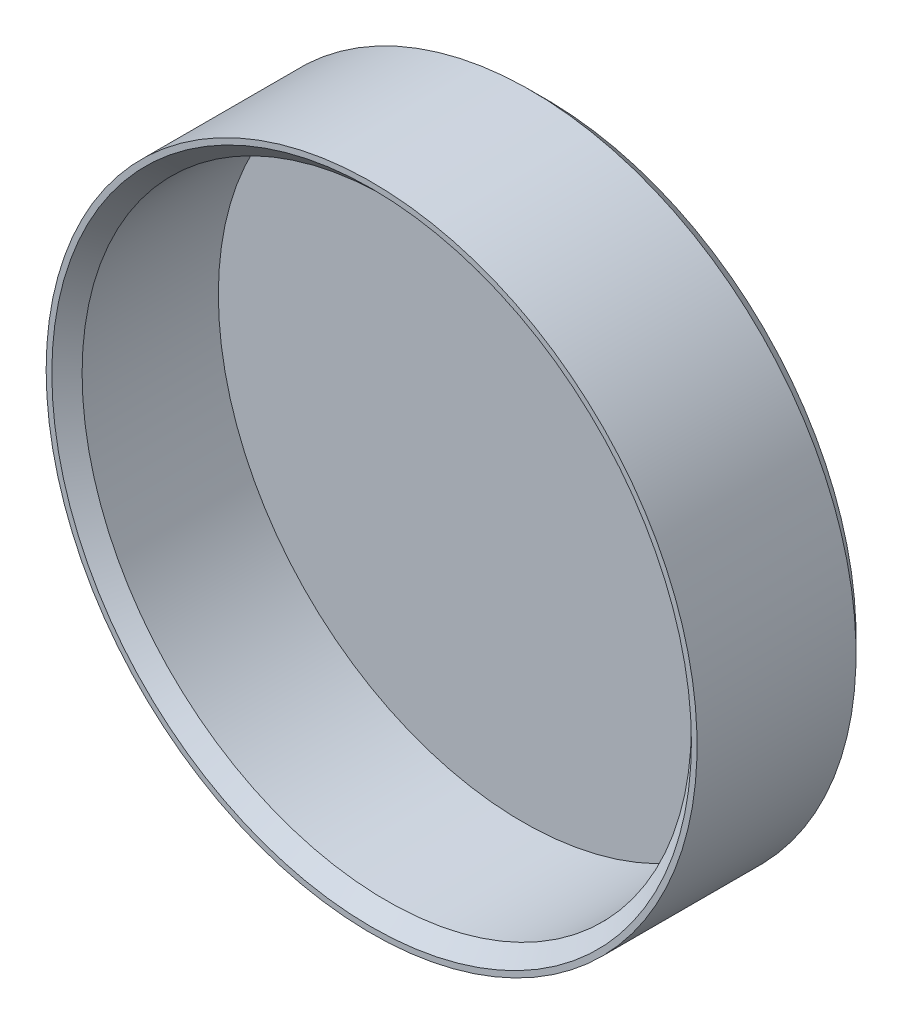
from build123d import *


with BuildPart() as part:
    # Esquisse1 → Révolution1 (revolve)
    with BuildSketch(Plane(origin=(0, 0, 0), x_dir=(0, 0, -1), z_dir=(1, 0, 0)), mode=Mode.PRIVATE) as r_volution1_sk:
        Polygon((0, 0), (0, 40.25), (-18, 40.25), (-20, 42.25), (-20, 43), (1, 43), (3, 41), (3, 0), align=None)
    revolve(r_volution1_sk.sketch.rotate(Axis((0, 0, -3), (0, 0, 1)), 90), axis=Axis((0, 0, -3), (0, 0, 1)))  # turned: the seam where the file's is


solid = part.part
